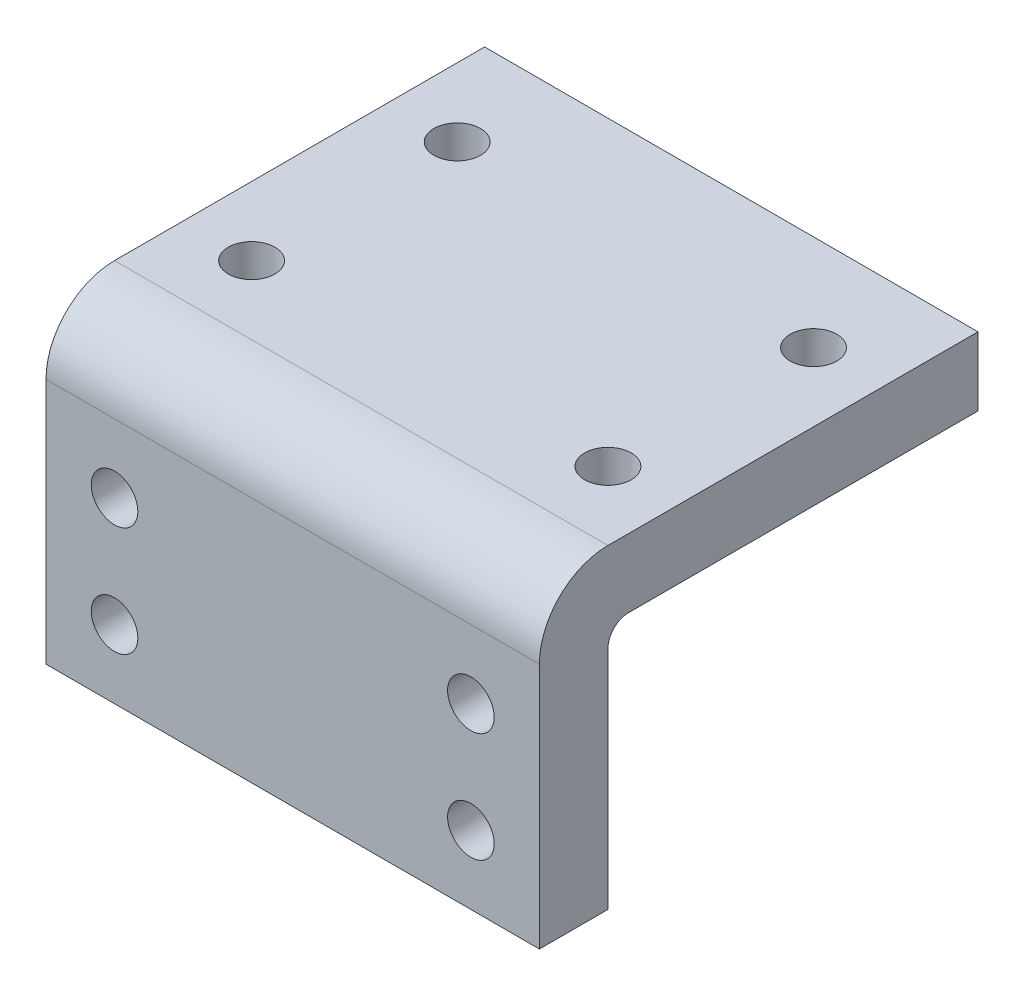
from build123d import *

# Parameters (mm, degrees)
SKETCH1_W                                       = 36
SKETCH1_H                                       = 18
BOSS_EXTRUDE1_DEPTH                             = 5
CSK_FOR_M3_FLAT_HEAD_MACHINE_SCREW1_D           = 3.4
CSK_FOR_M3_FLAT_HEAD_MACHINE_SCREW1_DEPTH       = 5
CSK_FOR_M3_FLAT_HEAD_MACHINE_SCREW1_CSINK_D     = 6.3
CSK_FOR_M3_FLAT_HEAD_MACHINE_SCREW1_CSINK_ANGLE = 90
SKETCH7_W                                       = 36
SKETCH7_H                                       = 32
BOSS_EXTRUDE2_DEPTH                             = 5
CSK_FOR_M3_FLAT_HEAD_MACHINE_SCREW2_D           = 3.4
CSK_FOR_M3_FLAT_HEAD_MACHINE_SCREW2_DEPTH       = 5
CSK_FOR_M3_FLAT_HEAD_MACHINE_SCREW2_CSINK_D     = 6.3
CSK_FOR_M3_FLAT_HEAD_MACHINE_SCREW2_CSINK_ANGLE = 90
FILLET1_R                                       = 1.5
FILLET2_R                                       = 5


with BuildPart() as part:
    # Sketch1 → Boss-Extrude1 (new body)
    with BuildSketch(Plane.XY):
        with Locations((18, 9)):
            Rectangle(SKETCH1_W, SKETCH1_H)
    extrude(amount=BOSS_EXTRUDE1_DEPTH)

    # CSK for M3 Flat Head Machine Screw1
    with Locations(Plane(origin=(0, 0, 0), x_dir=(-1, 0, 0), z_dir=(0, 0, -1))):
        with Locations((-31, 13), (-31, 5), (-5, 5), (-5, 13)):
            CounterSinkHole(CSK_FOR_M3_FLAT_HEAD_MACHINE_SCREW1_D / 2, CSK_FOR_M3_FLAT_HEAD_MACHINE_SCREW1_CSINK_D / 2, depth=CSK_FOR_M3_FLAT_HEAD_MACHINE_SCREW1_DEPTH, counter_sink_angle=CSK_FOR_M3_FLAT_HEAD_MACHINE_SCREW1_CSINK_ANGLE)

    # Sketch7 → Boss-Extrude2 (add)
    with BuildSketch(Plane(origin=(0, 18, 0), x_dir=(1, 0, 0), z_dir=(0, 1, 0))):
        with Locations((18, 11)):
            Rectangle(SKETCH7_W, SKETCH7_H)
    extrude(amount=BOSS_EXTRUDE2_DEPTH)

    # CSK for M3 Flat Head Machine Screw2
    with Locations(Plane(origin=(0, 18, 0), x_dir=(-1, 0, 0), z_dir=(0, -1, 0))):
        with Locations((-31, 5), (-31, 20), (-5, 20), (-5, 5)):
            CounterSinkHole(CSK_FOR_M3_FLAT_HEAD_MACHINE_SCREW2_D / 2, CSK_FOR_M3_FLAT_HEAD_MACHINE_SCREW2_CSINK_D / 2, depth=CSK_FOR_M3_FLAT_HEAD_MACHINE_SCREW2_DEPTH, counter_sink_angle=CSK_FOR_M3_FLAT_HEAD_MACHINE_SCREW2_CSINK_ANGLE)

    # Fillet1
    fillet1_edges = [part.edges().sort_by_distance(p)[0] for p in [
        (18, 18, 0),
    ]]
    fillet(fillet1_edges, radius=FILLET1_R)

    # Fillet2
    fillet2_edges = [part.edges().sort_by_distance(p)[0] for p in [
        (18, 23, 5),
    ]]
    fillet(fillet2_edges, radius=FILLET2_R)


solid = part.part
